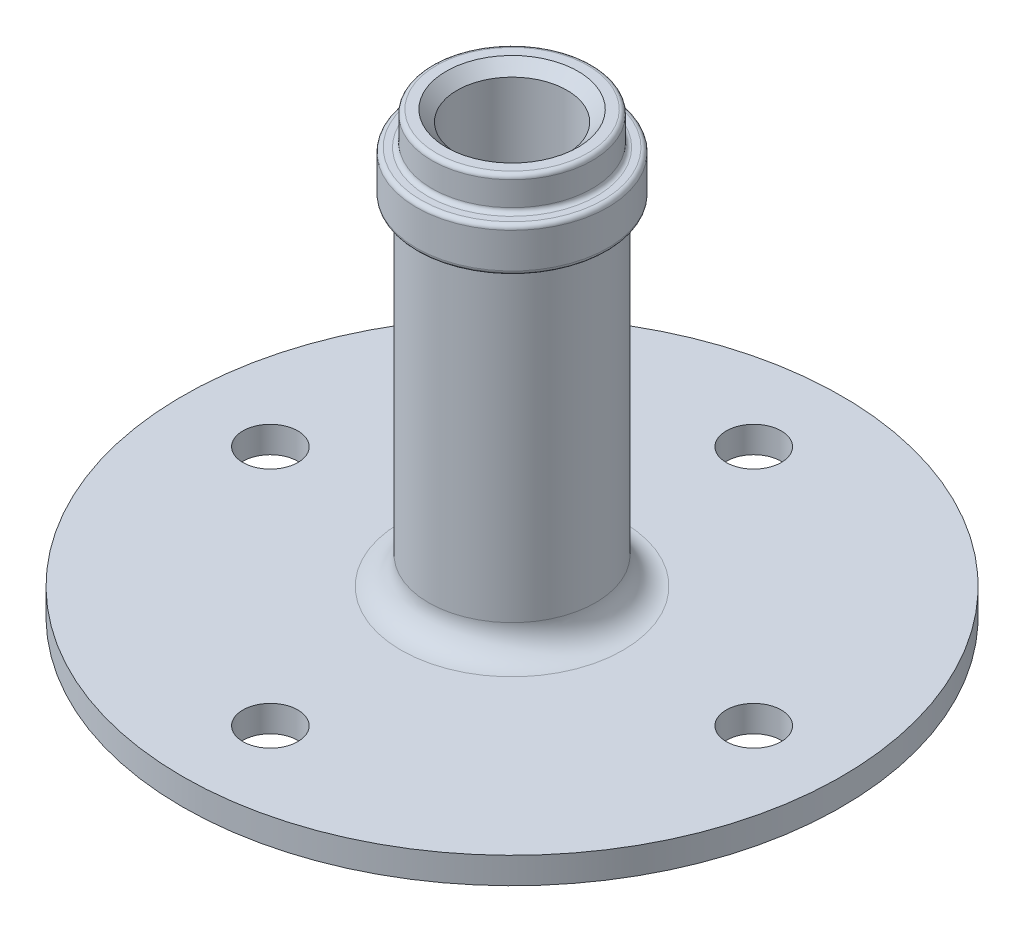
from build123d import *

# Parameters (mm, degrees)
SKETCH2_R          = 1.5875
CUT_EXTRUDE1_DEPTH = 2.524


with BuildPart() as part:
    # Sketch1 → Revolve1 (revolve)
    with BuildSketch(Plane.XY):
        with BuildLine():
            Line((4.6355, 25.146), (4.6355, 23.749))
            ThreePointArc((4.6355, 23.749), (4.709894878, 23.569394878), (4.8895, 23.495))
            Line((4.8895, 23.495), (5.2705, 23.495))
            ThreePointArc((5.2705, 23.495), (5.450105122, 23.420605122), (5.5245, 23.241))
            Line((5.5245, 23.241), (5.5245, 21.209))
            ThreePointArc((5.5245, 21.209), (5.450105122, 21.029394878), (5.2705, 20.955))
            Line((5.2705, 20.955), (5.08, 20.955))
            ThreePointArc((5.08, 20.955), (4.900394878, 20.880605122), (4.826, 20.701))
            Line((4.826, 20.701), (4.826, 3.1115))
            ThreePointArc((4.826, 3.1115), (5.290967985, 1.988967985), (6.4135, 1.524))
            Line((6.4135, 1.524), (19.05, 1.524))
            Line((19.05, 1.524), (19.05, 0))
            Line((19.05, 0), (3.175, 0))
            Line((3.175, 0), (3.175, 24.765))
            Line((3.175, 24.765), (3.81, 25.4))
            Line((3.81, 25.4), (4.3815, 25.4))
            ThreePointArc((4.3815, 25.4), (4.561105122, 25.325605122), (4.6355, 25.146))
        make_face()
    revolve(axis=Axis((0, 26.6065, 0), (0, -1, 0)))

    # Sketch2 → Cut-Extrude1 (cut, through all)
    with BuildSketch(Plane(origin=(0, 1.524, 0), x_dir=(1, 0, 0), z_dir=(0, 1, 0))):
        with Locations((0, 13.97)):
            Circle(SKETCH2_R)
        with Locations((13.97, 0)):
            Circle(SKETCH2_R)
        with Locations((0, -13.97)):
            Circle(SKETCH2_R)
        with Locations((-13.97, 0)):
            Circle(SKETCH2_R)
    extrude(amount=-CUT_EXTRUDE1_DEPTH, mode=Mode.SUBTRACT)


solid = part.part
